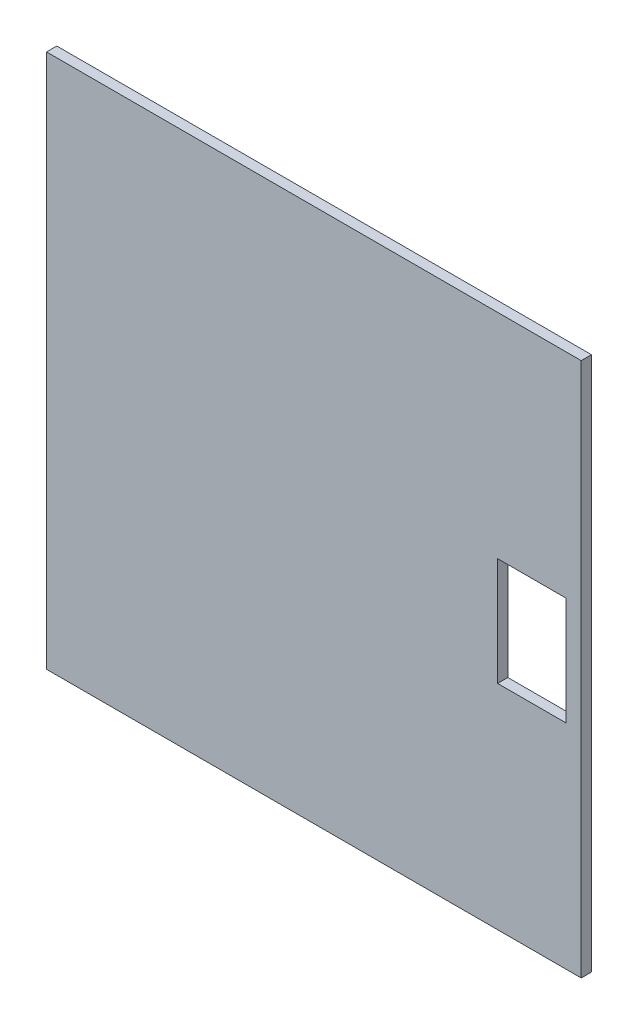
from build123d import *

# Parameters (mm, degrees)
SZKIC1_W                    = 470
SZKIC1_H                    = 470
DODANIE_WYCI_GNI_CIE2_DEPTH = 9
SZKIC5_W                    = 60
SZKIC5_H                    = 95
WYTNIJ_WYCI_GNI_CIE1_DEPTH  = 10


with BuildPart() as part:
    # Szkic1 → Dodanie-wyciągnięcie2 (new body)
    with BuildSketch(Plane.XY):
        with Locations((235, 235)):
            Rectangle(SZKIC1_W, SZKIC1_H)
    extrude(amount=-DODANIE_WYCI_GNI_CIE2_DEPTH)

    # Szkic5 → Wytnij-wyciągnięcie1 (cut)
    with BuildSketch(Plane.XY):
        with Locations((426.5, 235)):
            Rectangle(SZKIC5_W, SZKIC5_H)
    extrude(amount=-WYTNIJ_WYCI_GNI_CIE1_DEPTH, mode=Mode.SUBTRACT)


solid = part.part
